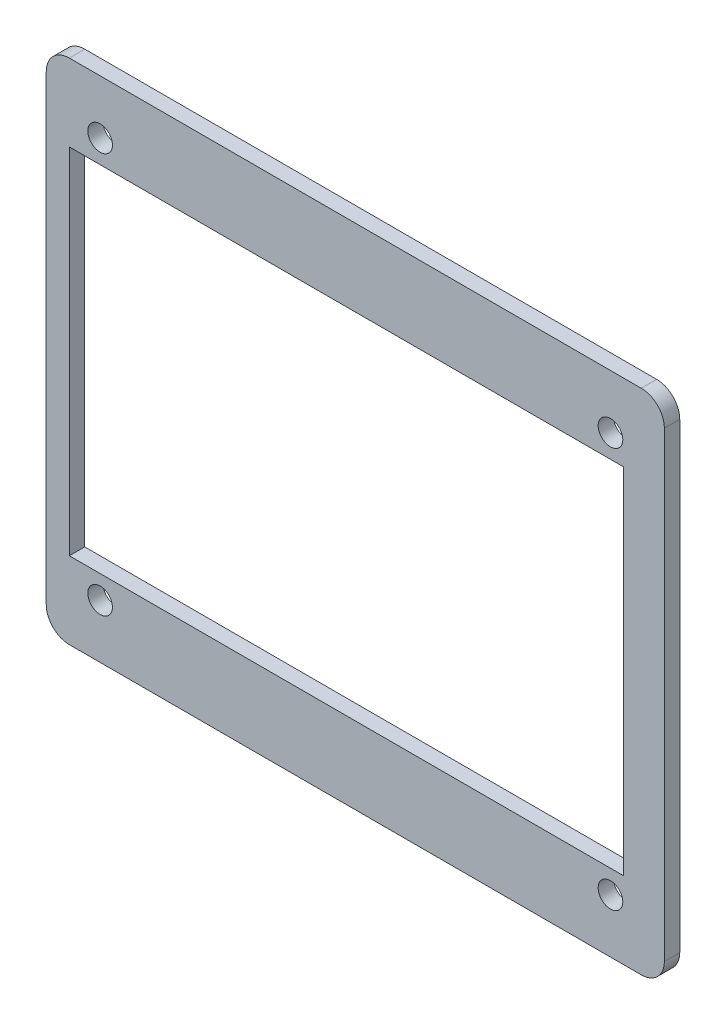
from build123d import *

# Parameters (mm, degrees)
SKETCH1_W                  = 80.3
SKETCH1_H                  = 66
BOSS_EXTRUDE1_DEPTH        = 2
F_3_2_3_2_DIAMETER_HOLE1_D = 3.2
FILLET1_R                  = 3
SKETCH4_W                  = 72
SKETCH4_H                  = 46
CUT_EXTRUDE1_DEPTH         = 3


with BuildPart() as part:
    # Sketch1 → Boss-Extrude1 (new body)
    with BuildSketch(Plane.XY):
        with Locations((40.15, 33)):
            Rectangle(SKETCH1_W, SKETCH1_H)
    extrude(amount=BOSS_EXTRUDE1_DEPTH)

    # Ø3.2 (3.2) Diameter Hole1 (through all)
    with Locations(Plane.XY.offset(2)):
        with Locations((7, 59), (73.3, 59), (73.3, 7), (7, 7)):
            Hole(F_3_2_3_2_DIAMETER_HOLE1_D / 2)

    # Fillet1
    fillet1_edges = [part.edges().sort_by_distance(p)[0] for p in [
        (0, 66, 1),
        (80.3, 66, 1),
        (80.3, 0, 1),
        (0, 0, 1),
    ]]
    fillet(fillet1_edges, radius=FILLET1_R)

    # Sketch4 → Cut-Extrude1 (cut, through all)
    with BuildSketch(Plane.XY.offset(2)):
        with Locations((39, 33)):
            Rectangle(SKETCH4_W, SKETCH4_H)
    extrude(amount=-CUT_EXTRUDE1_DEPTH, mode=Mode.SUBTRACT)


solid = part.part
